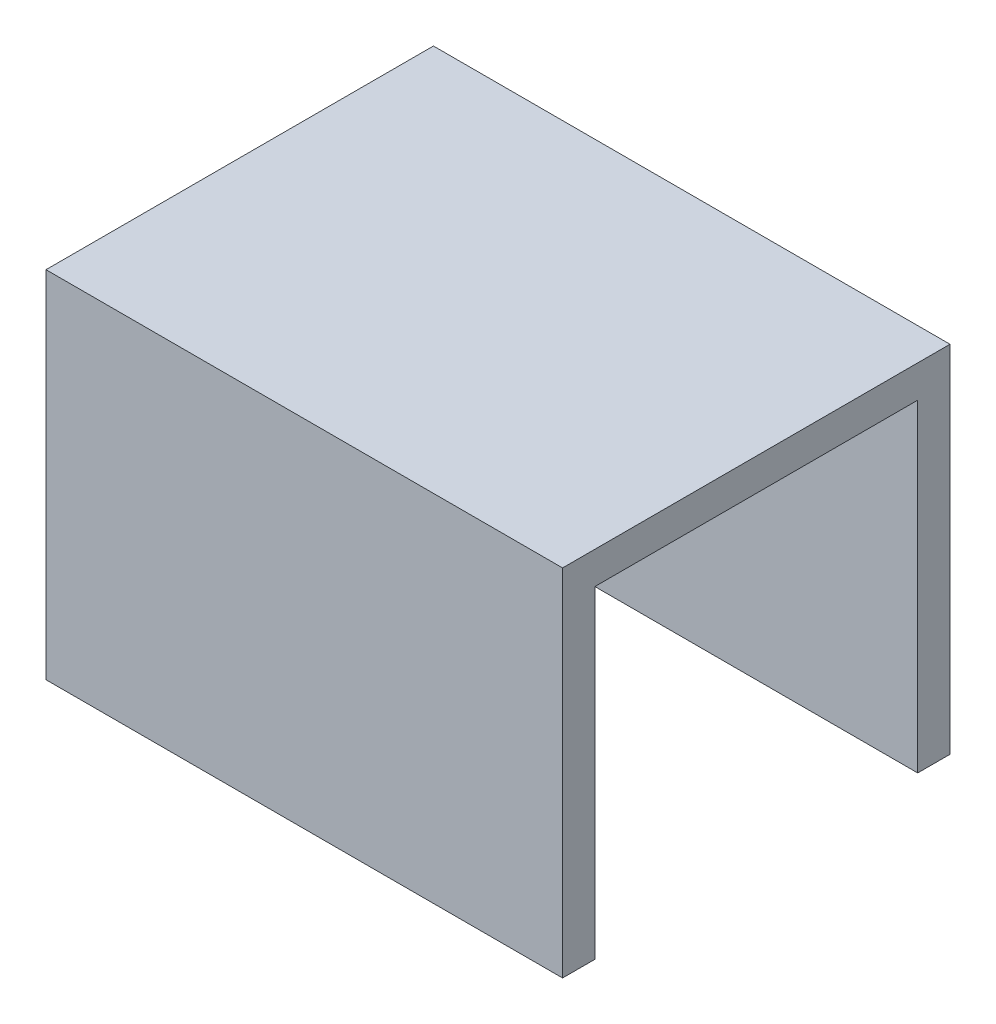
from build123d import *

# Parameters (mm, degrees)
EXTRUDE1_DEPTH = 25.4


with BuildPart() as part:
    # Sketch1 → Extrude1 (new body)
    with BuildSketch(Plane(origin=(0, 0, 0), x_dir=(0, 0, -1), z_dir=(1, 0, 0))):
        Polygon((-7.9375, 0), (-7.9375, 15.875), (7.9375, 15.875), (7.9375, 0), (9.525, 0), (9.525, 17.4625), (-9.525, 17.4625), (-9.525, 0), align=None)
    extrude(amount=EXTRUDE1_DEPTH)


solid = part.part
